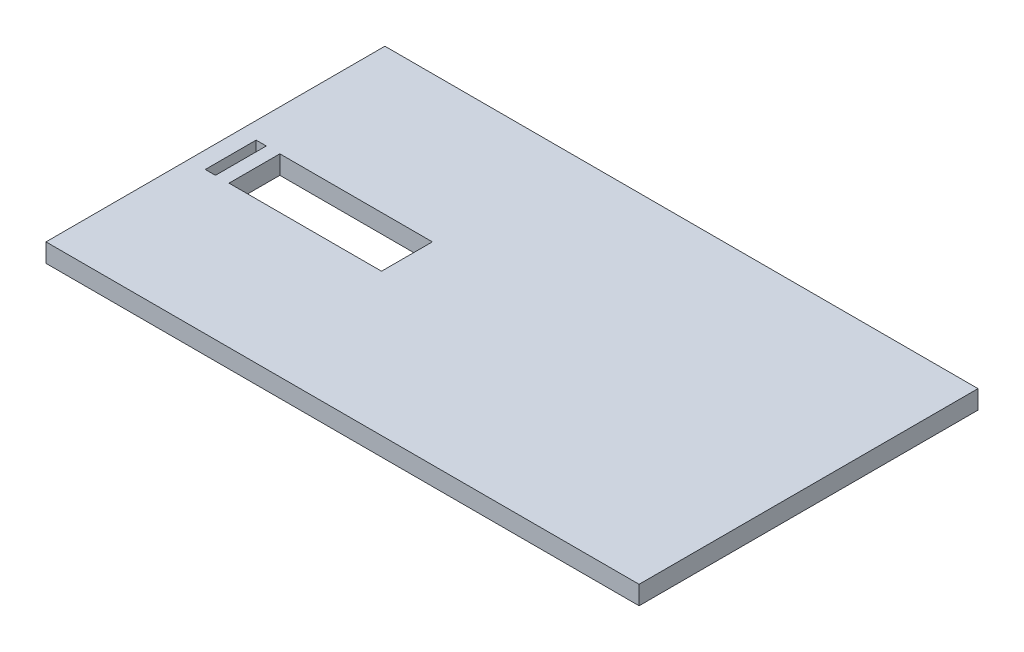
from build123d import *

# Parameters (mm, degrees)
SKETCH1_W               = 350
SKETCH1_H               = 200
BOSS_EXTRUDE1_DEPTH     = 11
SKETCH2_W               = 90
SKETCH2_H               = 30
SKETCH2_W_2             = 6
CUT_EXTRUDE1_DEPTH      = 1
CUT_EXTRUDE1_DEPTH_BACK = 12


with BuildPart() as part:
    # Sketch1 → Boss-Extrude1 (new body)
    with BuildSketch(Plane(origin=(0, 0, 0), x_dir=(1, 0, 0), z_dir=(0, 1, 0))):
        with Locations((32.608695652, -5.97826087)):
            Rectangle(SKETCH1_W, SKETCH1_H)
    extrude(amount=BOSS_EXTRUDE1_DEPTH)

    # Sketch2 → Cut-Extrude1 (cut, two sides)
    with BuildSketch(Plane(origin=(0, 11, 0), x_dir=(1, 0, 0), z_dir=(0, 1, 0))) as cut_extrude1_sk:
        with Locations((-73.391304348, -6.97826087)):
            Rectangle(SKETCH2_W, SKETCH2_H)
        with Locations((-129.391304348, -6.97826087)):
            Rectangle(SKETCH2_W_2, SKETCH2_H)
    extrude(amount=CUT_EXTRUDE1_DEPTH, mode=Mode.SUBTRACT)
    extrude(cut_extrude1_sk.sketch, amount=-CUT_EXTRUDE1_DEPTH_BACK, mode=Mode.SUBTRACT)


solid = part.part
